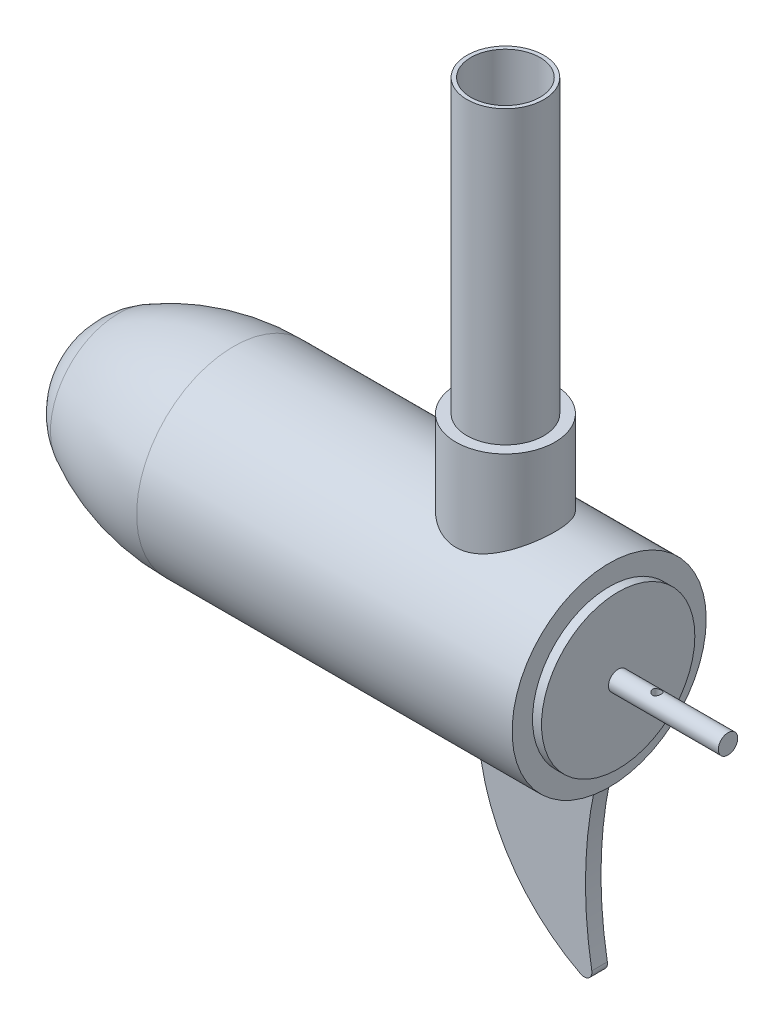
from build123d import *

# Parameters (mm, degrees)
SKETCH2_R                = 12.573
SKETCH2_R_2              = 11.303
BOSS_EXTRUDE1_DEPTH      = 635
BOSS_EXTRUDE3_DEPTH      = 2.54
BOSS_EXTRUDE3_DEPTH_BACK = 2.54
FILLET1_R                = 2.54
SKETCH5_R                = 16.1925
BOSS_EXTRUDE4_DEPTH      = 57.15
CUT_EXTRUDE1_DEPTH       = 651.960177358
CUT_EXTRUDE1_DEPTH_BACK  = 651.960177358
SKETCH6_W                = 25.146
SKETCH6_H                = 355.6
SKETCH7_R                = 36.277914584
CUT_EXTRUDE2_DEPTH       = 4.15798
SKETCH8_R                = 25.0825
BOSS_EXTRUDE5_DEPTH      = 2.9464
SKETCH9_R                = 3.175
BOSS_EXTRUDE6_DEPTH      = 35.941
CUT_EXTRUDE3_DEPTH       = 314.988077013
CUT_EXTRUDE3_DEPTH_BACK  = 314.988077013
SKETCH10_R               = 1.4224
SKETCH11_R               = 17.161337021
CUT_EXTRUDE4_DEPTH       = 127


with BuildPart() as part:
    # Sketch1 → Revolve1 (revolve)
    with BuildSketch(Plane.XY):
        with BuildLine():
            Line((38.1, 0), (38.1, 31.75))
            Line((38.1, 31.75), (-88.9, 31.75))
            ThreePointArc((-88.9, 31.75), (-108.34073355, 29.331909563), (-126.596722124, 22.225))
            ThreePointArc((-126.596722124, 22.225), (-136.180319261, 12.90006314), (-139.7, 0))
            Line((-139.7, 0), (38.1, 0))
        make_face()
    revolve(axis=Axis((0, 0, 0), (-1, 0, 0)))

    # Sketch2 → Boss-Extrude1 (add)
    with BuildSketch(Plane(origin=(0, 0, 0), x_dir=(1, 0, 0), z_dir=(0, 1, 0))):
        Circle(SKETCH2_R)
        Circle(SKETCH2_R_2, mode=Mode.SUBTRACT)
    extrude(amount=BOSS_EXTRUDE1_DEPTH)

    # Sketch4 → Boss-Extrude3 (add, two sides: drawn at the far end of the back side and taken through both)
    with BuildSketch(Plane.XY.offset(-BOSS_EXTRUDE3_DEPTH_BACK)):
        with BuildLine():
            Line((-6.35, -25.4), (-6.35, -31.75))
            ThreePointArc((-6.35, -31.75), (4.048186152, -66.092875899), (31.75, -88.9))
            ThreePointArc((31.75, -88.9), (28.726104864, -60.325), (31.75, -31.75))
            Line((31.75, -31.75), (31.75, -25.4))
            Line((31.75, -25.4), (-6.35, -25.4))
        make_face()
    extrude(amount=BOSS_EXTRUDE3_DEPTH + BOSS_EXTRUDE3_DEPTH_BACK)

    # Fillet1
    fillet1_edges = [part.edges().sort_by_distance(p)[0] for p in [
        (31.75, -88.9, 0),
    ]]
    fillet(fillet1_edges, radius=FILLET1_R)

    # Sketch5 → Boss-Extrude4 (add)
    with BuildSketch(Plane(origin=(0, 0, 0), x_dir=(1, 0, 0), z_dir=(0, 1, 0))):
        Circle(SKETCH5_R)
    extrude(amount=BOSS_EXTRUDE4_DEPTH)

    # Sketch6 → Cut-Extrude1 (cut, two sides: drawn at the far end of the back side and taken through both)
    with BuildSketch(Plane.XY.offset(-CUT_EXTRUDE1_DEPTH_BACK)):
        with Locations((0, 457.2)):
            Rectangle(SKETCH6_W, SKETCH6_H)
    extrude(amount=CUT_EXTRUDE1_DEPTH + CUT_EXTRUDE1_DEPTH_BACK, mode=Mode.SUBTRACT)

    # Sketch7 → Cut-Extrude2 (cut)
    with BuildSketch(Plane(origin=(38.1, 0, 0), x_dir=(0, 0, -1), z_dir=(1, 0, 0))):
        Circle(SKETCH7_R)
    extrude(amount=-CUT_EXTRUDE2_DEPTH, mode=Mode.SUBTRACT)

    # Sketch8 → Boss-Extrude5 (add)
    with BuildSketch(Plane(origin=(33.94202, 0, 0), x_dir=(0, 0, -1), z_dir=(1, 0, 0))):
        Circle(SKETCH8_R)
    extrude(amount=BOSS_EXTRUDE5_DEPTH)

    # Sketch9 → Boss-Extrude6 (add)
    with BuildSketch(Plane(origin=(36.88842, 0, 0), x_dir=(0, 0, -1), z_dir=(1, 0, 0))):
        Circle(SKETCH9_R)
    extrude(amount=BOSS_EXTRUDE6_DEPTH)

    # Sketch10 → Cut-Extrude3 (cut, two sides: drawn at the far end of the back side and taken through both)
    with BuildSketch(Plane(origin=(0, 0, 0), x_dir=(1, 0, 0), z_dir=(0, 1, 0)).offset(-CUT_EXTRUDE3_DEPTH_BACK)):
        with Locations((49.58842, 0)):
            Circle(SKETCH10_R)
    extrude(amount=CUT_EXTRUDE3_DEPTH + CUT_EXTRUDE3_DEPTH_BACK, mode=Mode.SUBTRACT)

    # Sketch11 → Cut-Extrude4 (cut)
    with BuildSketch(Plane(origin=(0, 279.4, 0), x_dir=(1, 0, 0), z_dir=(0, 1, 0))):
        Circle(SKETCH11_R)
    extrude(amount=-CUT_EXTRUDE4_DEPTH, mode=Mode.SUBTRACT)


solid = part.part
